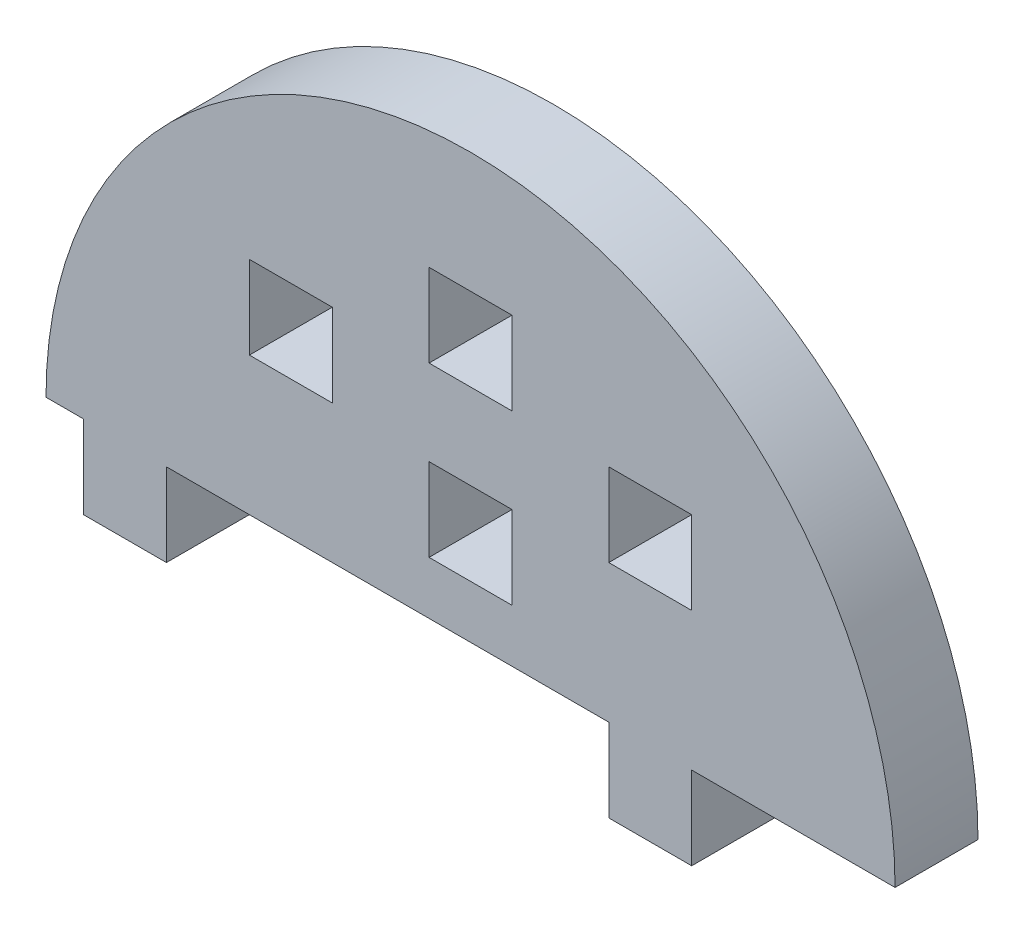
from build123d import *

# Parameters (mm, degrees)
MODEL_W             = 6
MODEL_H             = 6
BOSS_EXTRUDE1_DEPTH = 6


with BuildPart() as part:
    # Model → Boss-Extrude1 (new body)
    with BuildSketch(Plane.XY):
        with BuildLine():
            Line((3681.800276195, 1334.928711893), (3681.800276195, 1328.928711893))
            Line((3681.800276195, 1328.928711893), (3687.800276195, 1328.928711893))
            Line((3687.800276195, 1328.928711893), (3687.800276195, 1334.928711893))
            Line((3687.800276195, 1334.928711893), (3702.514561909, 1334.928711893))
            ThreePointArc((3702.514561909, 1334.928711893), (3671.800276195, 1365.642997607), (3641.08599048, 1334.928711893))
            Line((3641.08599048, 1334.928711893), (3643.800276195, 1334.928711893))
            Line((3643.800276195, 1334.928711893), (3643.800276195, 1328.928711893))
            Line((3643.800276195, 1328.928711893), (3649.800276195, 1328.928711893))
            Line((3649.800276195, 1328.928711893), (3649.800276195, 1334.928711893))
            Line((3649.800276195, 1334.928711893), (3681.800276195, 1334.928711893))
        make_face()
        with Locations((3684.800276195, 1347.928711893)):
            Rectangle(MODEL_W, MODEL_H, mode=Mode.SUBTRACT)
        with Locations((3658.800276195, 1347.928711893)):
            Rectangle(MODEL_W, MODEL_H, mode=Mode.SUBTRACT)
        with Locations((3671.800276195, 1353.928711893)):
            Rectangle(MODEL_W, MODEL_H, mode=Mode.SUBTRACT)
        with Locations((3671.800276195, 1341.753170727)):
            Rectangle(MODEL_W, MODEL_H, mode=Mode.SUBTRACT)
    extrude(amount=BOSS_EXTRUDE1_DEPTH)


solid = part.part
